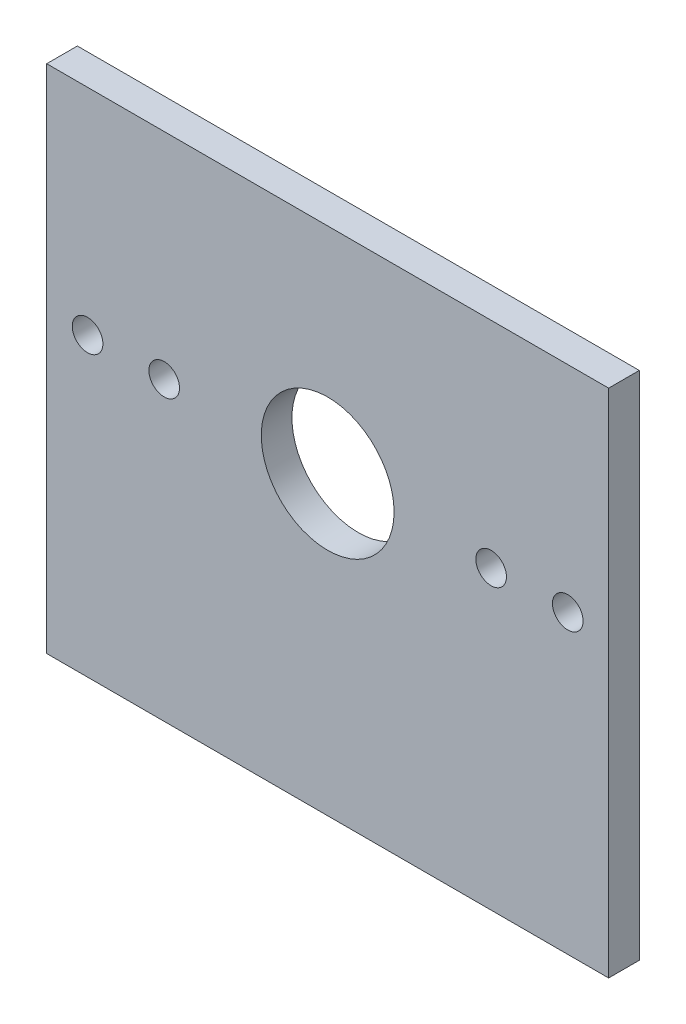
from build123d import *

# Parameters (mm, degrees)
ESQUISSE1_W        = 55
ESQUISSE1_H        = 50
ESQUISSE1_R        = 6.5
ESQUISSE1_R_2      = 1.5
BOSS_EXTRU_1_DEPTH = 3


with BuildPart() as part:
    # Esquisse1 → Boss.-Extru.1 (new body)
    with BuildSketch(Plane.XY):
        Rectangle(ESQUISSE1_W, ESQUISSE1_H)
        with Locations((0, 4)):
            Circle(ESQUISSE1_R, mode=Mode.SUBTRACT)
        with Locations((16, 4)):
            Circle(ESQUISSE1_R_2, mode=Mode.SUBTRACT)
        with Locations((23.5, 4)):
            Circle(ESQUISSE1_R_2, mode=Mode.SUBTRACT)
        with Locations((-16, 4)):
            Circle(ESQUISSE1_R_2, mode=Mode.SUBTRACT)
        with Locations((-23.5, 4)):
            Circle(ESQUISSE1_R_2, mode=Mode.SUBTRACT)
    extrude(amount=BOSS_EXTRU_1_DEPTH)


solid = part.part
